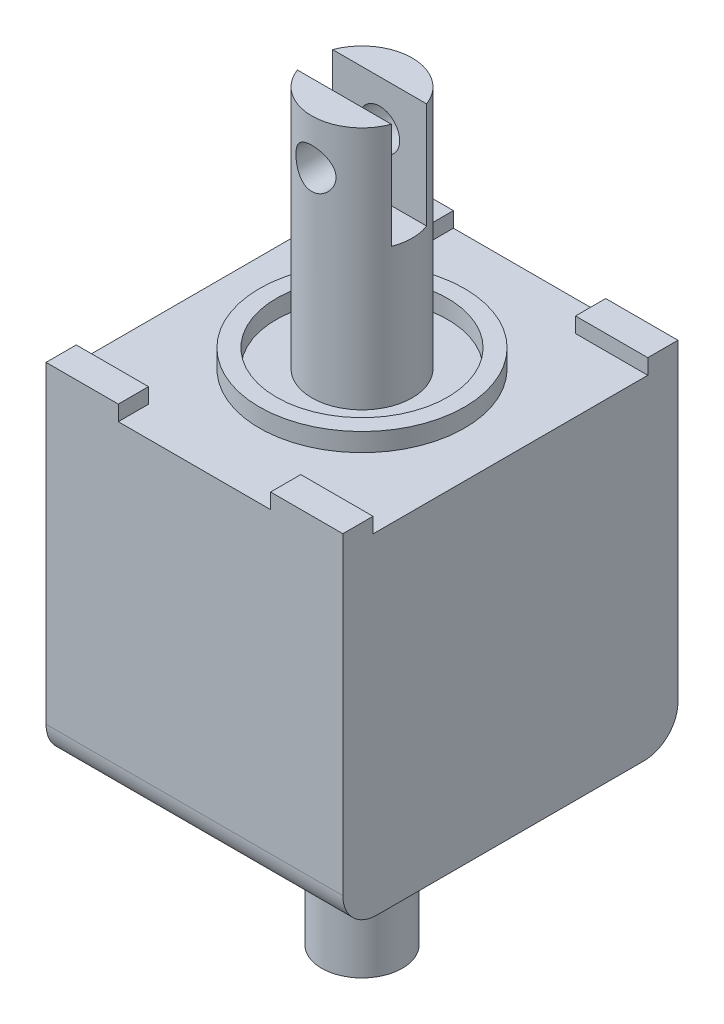
from build123d import *

# Parameters (mm, degrees)
SKETCH1_W                      = 22.225
SKETCH1_H                      = 25.0952
BOSS_EXTRUDE1_DEPTH            = 24.8666
SKETCH2_R                      = 3.0226
BOSS_EXTRUDE2_DEPTH            = 12.496800002
SKETCH3_R                      = 3.7592
BOSS_EXTRUDE3_DEPTH            = 18.288000094
SKETCH4_R                      = 7.6835
SKETCH4_R_2                    = 6.4135
BOSS_EXTRUDE4_DEPTH            = 1.3716
SKETCH5_W                      = 5.4102
SKETCH5_H                      = 2.2606
BOSS_EXTRUDE5_DEPTH            = 1.143
FILLET1_R                      = 2.54
CUT_EXTRUDE1_REACH             = 13.113
SKETCH6_W                      = 2.6416
SKETCH6_H                      = 7.9248
CUT_EXTRUDE1_DIRECTION_2_REACH = 13.112
CUT_EXTRUDE2_REACH             = 14.548
SKETCH7_R                      = 1.4986
CUT_EXTRUDE2_DIRECTION_2_REACH = 14.548


with BuildPart() as part:
    # Sketch1 → Boss-Extrude1 (new body)
    with BuildSketch(Plane(origin=(0, 0, 0), x_dir=(1, 0, 0), z_dir=(0, 1, 0))):
        Rectangle(SKETCH1_W, SKETCH1_H)
    extrude(amount=BOSS_EXTRUDE1_DEPTH)

    # Sketch2 → Boss-Extrude2 (add)
    with BuildSketch(Plane.XZ):
        Circle(SKETCH2_R)
    extrude(amount=BOSS_EXTRUDE2_DEPTH)

    # Sketch3 → Boss-Extrude3 (add)
    with BuildSketch(Plane(origin=(0, 24.8666, 0), x_dir=(1, 0, 0), z_dir=(0, 1, 0))):
        Circle(SKETCH3_R)
    extrude(amount=BOSS_EXTRUDE3_DEPTH)

    # Sketch4 → Boss-Extrude4 (add)
    with BuildSketch(Plane(origin=(0, 24.8666, 0), x_dir=(1, 0, 0), z_dir=(0, 1, 0))):
        Circle(SKETCH4_R)
        Circle(SKETCH4_R_2, mode=Mode.SUBTRACT)
    extrude(amount=BOSS_EXTRUDE4_DEPTH)

    # Sketch5 → Boss-Extrude5 (add)
    with BuildSketch(Plane(origin=(0, 24.8666, 0), x_dir=(1, 0, 0), z_dir=(0, 1, 0))):
        with Locations((-8.4074, -11.4173)):
            Rectangle(SKETCH5_W, SKETCH5_H)
        with Locations((8.4074, -11.4173)):
            Rectangle(SKETCH5_W, SKETCH5_H)
        with Locations((8.4074, 11.4173)):
            Rectangle(SKETCH5_W, SKETCH5_H)
        with Locations((-8.4074, 11.4173)):
            Rectangle(SKETCH5_W, SKETCH5_H)
    extrude(amount=BOSS_EXTRUDE5_DEPTH)

    # Fillet1
    fillet1_edges = [part.edges().sort_by_distance(p)[0] for p in [
        (0, 0, 12.5476),
        (0, 0, -12.5476),
    ]]
    fillet(fillet1_edges, radius=FILLET1_R)

    # Sketch6 → Cut-Extrude1 (cut, up to next)
    with BuildSketch(Plane(origin=(0, 0, 0), x_dir=(0, 0, -1), z_dir=(1, 0, 0)), mode=Mode.PRIVATE) as cut_extrude1_sk1:
        with Locations((0, 39.192200094)):
            Rectangle(SKETCH6_W, SKETCH6_H)
    cut_extrude1_tool1 = extrude(cut_extrude1_sk1.sketch, amount=-CUT_EXTRUDE1_REACH, mode=Mode.PRIVATE) & part.part
    add(cut_extrude1_tool1.solids().sort_by_distance((0, 39.1922, 0))[0], mode=Mode.SUBTRACT)

    # Sketch6 → Cut-Extrude1 direction 2 (cut, up to next)
    with BuildSketch(Plane(origin=(0, 0, 0), x_dir=(0, 0, -1), z_dir=(1, 0, 0)), mode=Mode.PRIVATE) as cut_extrude1_direction_2_sk1:
        with Locations((0, 39.192200094)):
            Rectangle(SKETCH6_W, SKETCH6_H)
    cut_extrude1_direction_2_tool1 = extrude(cut_extrude1_direction_2_sk1.sketch, amount=CUT_EXTRUDE1_DIRECTION_2_REACH, mode=Mode.PRIVATE) & part.part
    add(cut_extrude1_direction_2_tool1.solids().sort_by_distance((0, 39.1922, 0))[0], mode=Mode.SUBTRACT)

    # Sketch7 → Cut-Extrude2 (cut, up to next)
    with BuildSketch(Plane.XY, mode=Mode.PRIVATE) as cut_extrude2_sk1:
        with Locations((0, 39.751000094)):
            Circle(SKETCH7_R)
    cut_extrude2_tool1 = extrude(cut_extrude2_sk1.sketch, amount=-CUT_EXTRUDE2_REACH, mode=Mode.PRIVATE) & part.part
    add(cut_extrude2_tool1.solids().sort_by_distance((0, 39.751, 0))[0], mode=Mode.SUBTRACT)

    # Sketch7 → Cut-Extrude2 direction 2 (cut, up to next)
    with BuildSketch(Plane.XY, mode=Mode.PRIVATE) as cut_extrude2_direction_2_sk1:
        with Locations((0, 39.751000094)):
            Circle(SKETCH7_R)
    cut_extrude2_direction_2_tool1 = extrude(cut_extrude2_direction_2_sk1.sketch, amount=CUT_EXTRUDE2_DIRECTION_2_REACH, mode=Mode.PRIVATE) & part.part
    add(cut_extrude2_direction_2_tool1.solids().sort_by_distance((0, 39.751, 0))[0], mode=Mode.SUBTRACT)


solid = part.part
